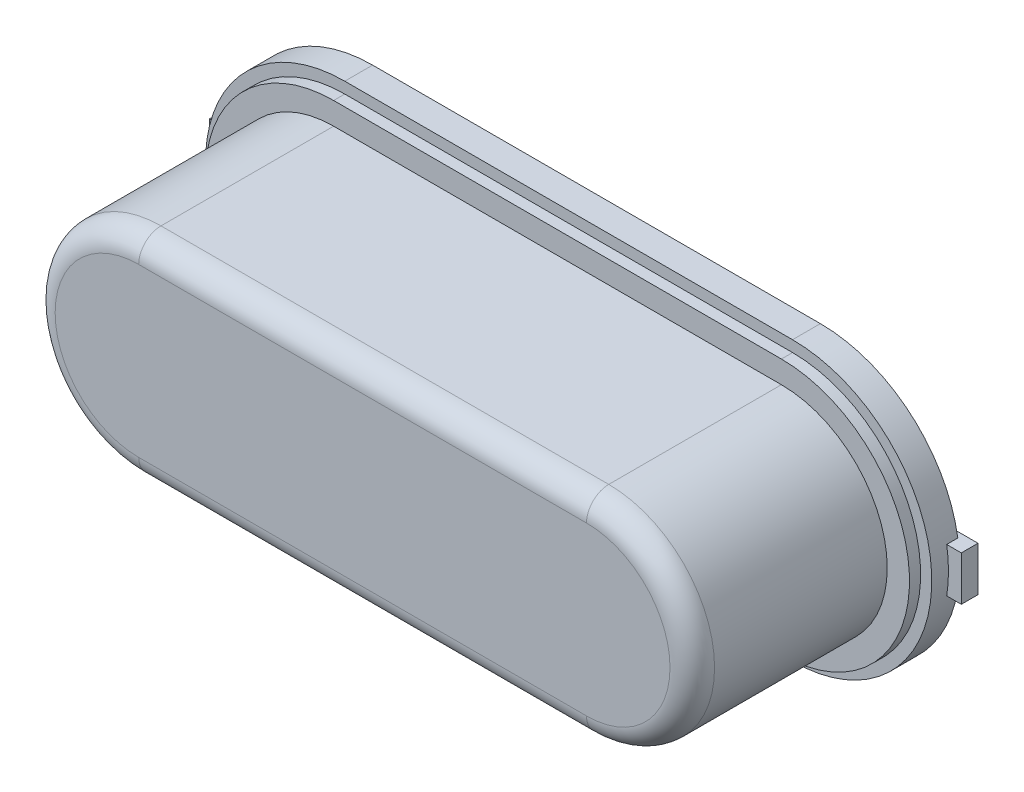
from build123d import *

# Parameters (mm, degrees)
BOSS_EXTRUDE1_DEPTH = 4.3
CUT_EXTRUDE1_START  = 0.8
SKETCH2_OUTSIDE_W   = 17.962
SKETCH2_OUTSIDE_H   = 9.922
CUT_EXTRUDE1_DEPTH  = 4.5
FILLET1_R           = 0.4
CUT_EXTRUDE2_START  = 0.6
SKETCH3_OUTSIDE_W   = 17.962
SKETCH3_OUTSIDE_H   = 9.922
CUT_EXTRUDE2_DEPTH  = 4.7
SKETCH5_W           = 15.203925075
SKETCH5_H           = 7.601962538
CUT_EXTRUDE3_DEPTH  = 0.1
SKETCH6_W           = 4.55
SKETCH6_H           = 0.8
BOSS_EXTRUDE2_DEPTH = 0.3


with BuildPart() as part:
    # Sketch1 → Boss-Extrude1 (new body)
    with BuildSketch(Plane.XY):
        with BuildLine():
            Line((-4.019954666, 2.5), (4.019954666, 2.5))
            ThreePointArc((4.019954666, 2.5), (6.519954666, 0), (4.019954666, -2.5))
            Line((4.019954666, -2.5), (-4.019954666, -2.5))
            ThreePointArc((-4.019954666, -2.5), (-6.519954666, 0), (-4.019954666, 2.5))
        make_face()
    extrude(amount=BOSS_EXTRUDE1_DEPTH)

    # Sketch2 outside → Cut-Extrude1 (cut, through all)
    with BuildSketch(Plane.XY.offset(CUT_EXTRUDE1_START)):
        Rectangle(SKETCH2_OUTSIDE_W, SKETCH2_OUTSIDE_H)
        with BuildLine():
            Line((-4.019954666, 1.9), (4.019954666, 1.9))
            ThreePointArc((4.019954666, 1.9), (5.919954666, 0), (4.019954666, -1.9))
            Line((4.019954666, -1.9), (-4.019954666, -1.9))
            ThreePointArc((-4.019954666, -1.9), (-5.919954666, 0), (-4.019954666, 1.9))
        make_face(mode=Mode.SUBTRACT)
    extrude(amount=CUT_EXTRUDE1_DEPTH, mode=Mode.SUBTRACT)

    # Fillet1
    fillet1_edges = [part.edges().sort_by_distance(p)[0] for p in [
        (-5.919954666, 0, 4.3),
        (0, -1.9, 4.3),
        (5.919954666, 0, 4.3),
        (0, 1.9, 4.3),
    ]]
    fillet(fillet1_edges, radius=FILLET1_R)

    # Sketch3 outside → Cut-Extrude2 (cut, through all)
    with BuildSketch(Plane.XY.offset(CUT_EXTRUDE2_START)):
        Rectangle(SKETCH3_OUTSIDE_W, SKETCH3_OUTSIDE_H)
        with BuildLine():
            Line((-4.019954666, 2.3), (4.019954666, 2.3))
            ThreePointArc((4.019954666, 2.3), (6.319954666, 0), (4.019954666, -2.3))
            Line((4.019954666, -2.3), (-4.019954666, -2.3))
            ThreePointArc((-4.019954666, -2.3), (-6.319954666, 0), (-4.019954666, 2.3))
        make_face(mode=Mode.SUBTRACT)
    extrude(amount=CUT_EXTRUDE2_DEPTH, mode=Mode.SUBTRACT)

    # Sketch5 → Cut-Extrude3 (cut)
    with BuildSketch(Plane.XY):
        with Locations((0.247324124, -0.273358242)):
            Rectangle(SKETCH5_W, SKETCH5_H)
    extrude(amount=CUT_EXTRUDE3_DEPTH, mode=Mode.SUBTRACT)

    # Sketch6 → Boss-Extrude2 (add)
    with BuildSketch(Plane.XY):
        with Locations((-4.475, 0)):
            Rectangle(SKETCH6_W, SKETCH6_H)
        with Locations((4.475, 0)):
            Rectangle(SKETCH6_W, SKETCH6_H)
    extrude(amount=BOSS_EXTRUDE2_DEPTH)


solid = part.part
